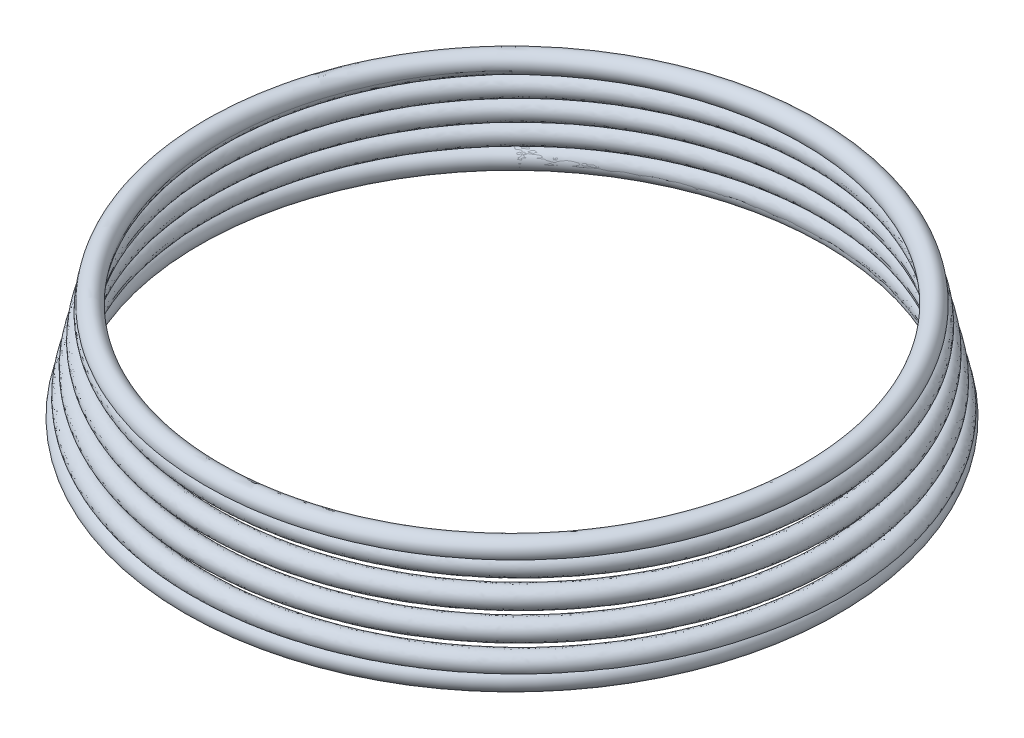
from build123d import *

# Parameters (mm, degrees)
CROQUIS1_R          = 0.175
BARRER1_PITCH       = 0.434787234
BARRER1_HEIGHT      = 1.7
BARRER1_RADIUS      = 5.55
BARRER1_START_ANGLE = -135
CROQUIS6_R          = 0.175
CROQUIS7_R          = 0.175


with BuildPart() as part:
    # Croquis1 → Revolución1 (revolve)
    with BuildSketch(Plane.XY, mode=Mode.PRIVATE) as revoluci_n1_sk:
        with Locations((5.55, 0)):
            Circle(CROQUIS1_R)
    revolve(revoluci_n1_sk.sketch.rotate(Axis((0, 0, 0), (0, 1, 0)), 90), axis=Axis((0, 0, 0), (0, 1, 0)))


with BuildPart() as body_2:
    # Barrer1: sweep along a helix
    with BuildLine() as barrer1_path:
        # a taper helix: rise per turn along the axis 0.425, along the cone's slant (build123d's pitch) 0.434787234
        add(Helix(BARRER1_PITCH, BARRER1_HEIGHT, BARRER1_RADIUS, center=(0, 0, 0), direction=(0, 1, 0), cone_angle=-12.18, lefthand=True, mode=Mode.PRIVATE).rotate(Axis((0, 0, 0), (0, 1, 0)), BARRER1_START_ANGLE))
    # Croquis6 → Barrer1 (sweep)
    with BuildSketch(Plane(origin=(-3.664982597, 1.7, -3.664982597), x_dir=(-0.7010042747742905, -0.09551111674032402, -0.706732363294046), z_dir=(0.7090353833285041, 0.01304918670317642, -0.7050521568753527))):
        Circle(CROQUIS6_R)
    sweep(path=barrer1_path.line, is_frenet=True)

    # Croquis7 → Revolución2 (revolve)
    with BuildSketch(Plane(origin=(0, 0, 0), x_dir=(0.7071067811865542, 0, 0.7071067811865408), z_dir=(-0.7071067811865408, 0, 0.7071067811865542)), mode=Mode.PRIVATE) as revoluci_n2_sk:
        with Locations((-5.183068095, 1.7)):
            Circle(CROQUIS7_R)
    revolve(revoluci_n2_sk.sketch.rotate(Axis((0, 0, 0), (0, 1, 0)), 337.493585784), axis=Axis((0, 0, 0), (0, 1, 0)))


solid = Compound([part.part, body_2.part])
